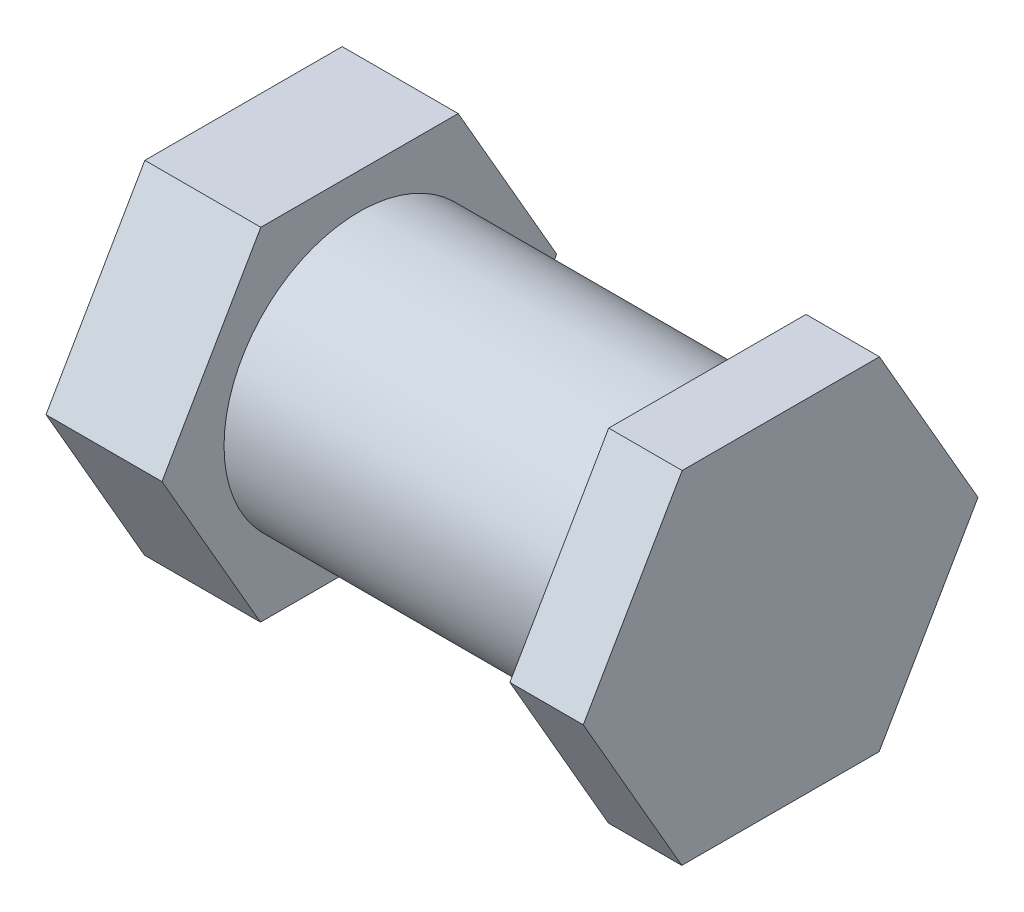
from build123d import *

# Parameters (mm, degrees)
SKETCH1_R                = 3.5
BOSS_EXTRUDE1_DEPTH      = 3
BOSS_EXTRUDE1_DEPTH_BACK = 9
BOSS_EXTRUDE2_DEPTH      = 3
BOSS_EXTRUDE3_DEPTH      = 1.9


with BuildPart() as part:
    # Sketch1 → Boss-Extrude1 (new body, two sides)
    with BuildSketch(Plane.ZY.offset(-64.468173267)) as boss_extrude1_sk:
        with Locations((260.861627804, 7.55)):
            Circle(SKETCH1_R)
    extrude(amount=BOSS_EXTRUDE1_DEPTH)
    extrude(boss_extrude1_sk.sketch, amount=-BOSS_EXTRUDE1_DEPTH_BACK)

    # Sketch2 → Boss-Extrude2 (add)
    with BuildSketch(Plane.ZY.offset(-61.468173267)):
        Polygon((263.418922822, 3.130759561), (265.967449799, 7.555062231), (263.410154781, 11.974302669), (258.304332787, 11.969240439), (255.75580581, 7.544937769), (258.313100828, 3.125697331), align=None)
    extrude(amount=-BOSS_EXTRUDE2_DEPTH)

    # Sketch3 → Boss-Extrude3 (add)
    with BuildSketch(Plane(origin=(73.468173267, 0, 0), x_dir=(0, 0, -1), z_dir=(1, 0, 0))):
        Polygon((-258.313100828, 3.125697331), (-255.75580581, 7.544937769), (-258.304332787, 11.969240439), (-263.410154781, 11.974302669), (-265.967449799, 7.555062231), (-263.418922822, 3.130759561), align=None)
    extrude(amount=BOSS_EXTRUDE3_DEPTH)


solid = part.part
